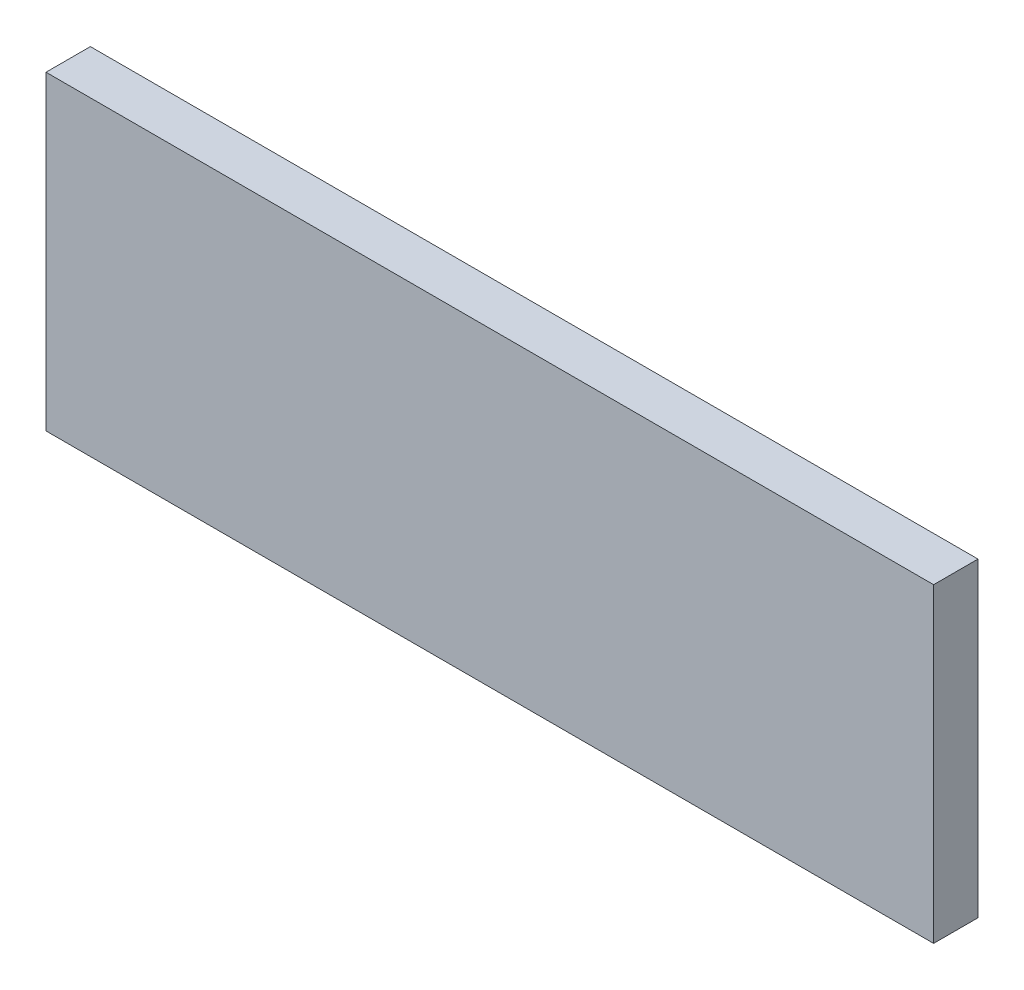
from build123d import *

# Parameters (mm, degrees)
SKETCH1_W           = 254
SKETCH1_H           = 88.9
BOSS_EXTRUDE1_DEPTH = 12.7


with BuildPart() as part:
    # Sketch1 → Boss-Extrude1 (new body)
    with BuildSketch(Plane.XY):
        with Locations((1.704697987, 29.772550336)):
            Rectangle(SKETCH1_W, SKETCH1_H)
    extrude(amount=BOSS_EXTRUDE1_DEPTH)


solid = part.part
